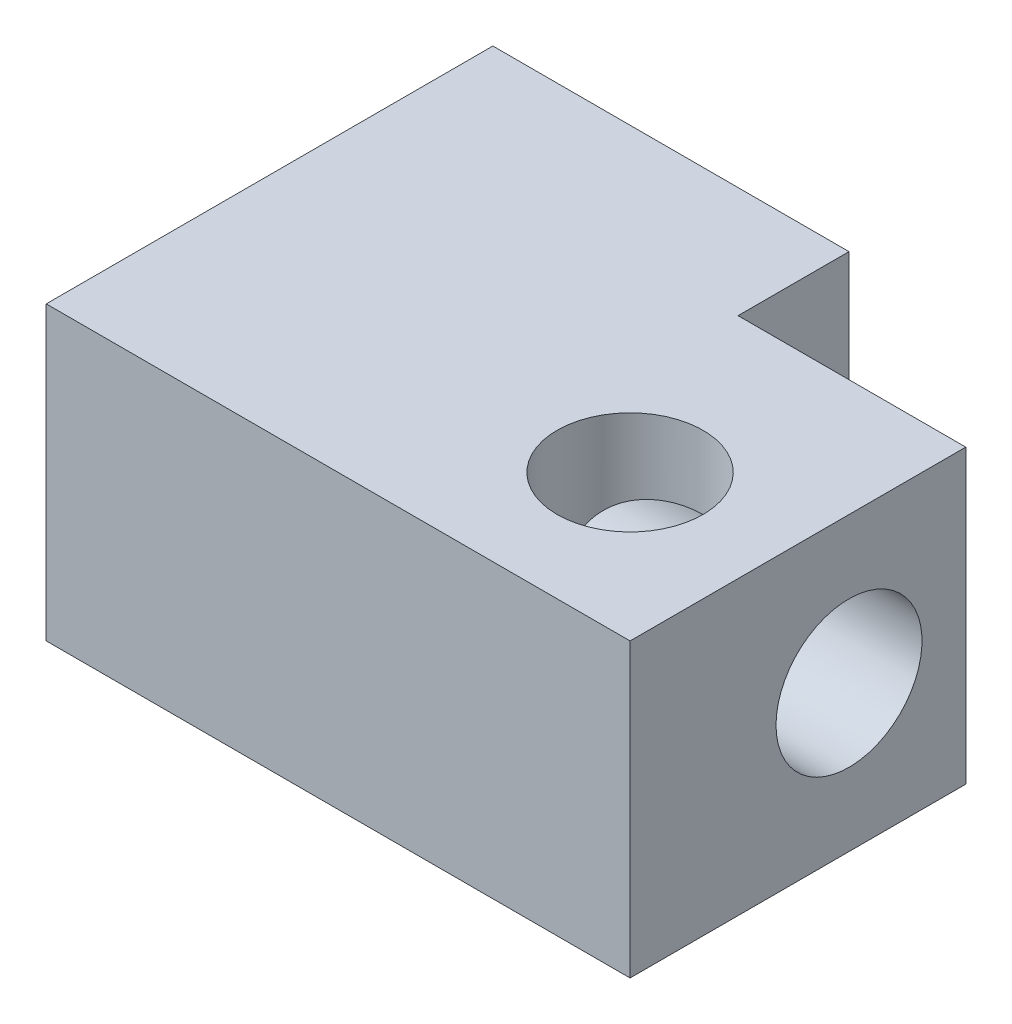
from build123d import *

# Parameters (mm, degrees)
SKETCH4_R           = 1.25
BOSS_EXTRUDE1_DEPTH = 5
CUT_EXTRUDE1_DEPTH  = 10


with BuildPart() as part:
    # Sketch4 → Boss-Extrude1 (new body)
    with BuildSketch(Plane(origin=(0, 0, 0), x_dir=(1, 0, 0), z_dir=(0, 1, 0))):
        Polygon((7.5, -82.75), (7.5, -88.5), (-2.5, -88.5), (-2.5, -80.85), (3.6, -80.85), (3.6, -82.75), align=None)
        with Locations((5, -86)):
            Circle(SKETCH4_R, mode=Mode.SUBTRACT)
    extrude(amount=BOSS_EXTRUDE1_DEPTH)

    # Sketch5 → Cut-Extrude1 (cut)
    with BuildSketch(Plane.ZY.offset(2.5)):
        with BuildLine():
            ThreePointArc((84.75, 3.75), (83.5, 2.5), (84.75, 1.25))
            Line((84.75, 1.25), (84.75, 3.75))
        make_face()
        with BuildLine():
            Line((84.75, 3.75), (84.75, 1.25))
            ThreePointArc((84.75, 1.25), (85.633883476, 1.616116524), (86, 2.5))
            ThreePointArc((86, 2.5), (85.633883476, 3.383883476), (84.75, 3.75))
        make_face()
    extrude(amount=-CUT_EXTRUDE1_DEPTH, mode=Mode.SUBTRACT)


solid = part.part
